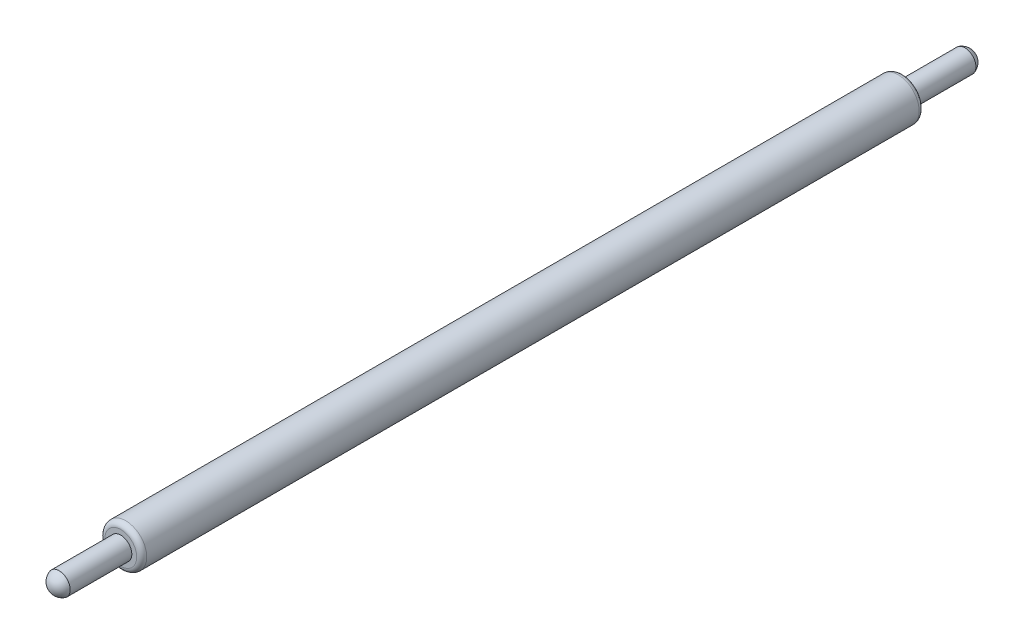
from build123d import *

# Parameters (mm, degrees)
ESQUISSE1_R             = 0.625
BOSS_EXTRU_1_DEPTH      = 11.662554
BOSS_EXTRU_1_DEPTH_BACK = 11.662554
ESQUISSE2_R             = 0.33
BOSS_EXTRU_2_DEPTH      = 1.837446
ESQUISSE3_R             = 0.33
BOSS_EXTRU_3_DEPTH      = 1.837446
D_ME1_FACE_RADIUS       = 0.33
D_ME1_HEIGHT            = 0.25
D_ME2_FACE_RADIUS       = 0.33
D_ME2_HEIGHT            = 0.25
CONG_1_R                = 0.15


with BuildPart() as part:
    # Esquisse1 → Boss.-Extru.1 (new body, two sides)
    with BuildSketch(Plane.XY) as boss_extru_1_sk:
        Circle(ESQUISSE1_R)
    extrude(amount=BOSS_EXTRU_1_DEPTH)
    extrude(boss_extru_1_sk.sketch, amount=-BOSS_EXTRU_1_DEPTH_BACK)

    # Esquisse2 → Boss.-Extru.2 (add)
    with BuildSketch(Plane.XY.offset(11.662554)):
        Circle(ESQUISSE2_R)
    extrude(amount=BOSS_EXTRU_2_DEPTH)

    # Esquisse3 → Boss.-Extru.3 (add)
    with BuildSketch(Plane(origin=(0, 0, -11.662554), x_dir=(-1, 0, 0), z_dir=(0, 0, -1))):
        Circle(ESQUISSE3_R)
    extrude(amount=BOSS_EXTRU_3_DEPTH)

    # D_me1: a dome of height H over a round flat face of radius A is a cap of a sphere of radius (A * A + H * H) / (2 * H)
    d_me1_r = (D_ME1_FACE_RADIUS * D_ME1_FACE_RADIUS + D_ME1_HEIGHT * D_ME1_HEIGHT) / (2 * D_ME1_HEIGHT)
    d_me1_base = Plane((0, 0, 13.5), z_dir=(0, 0, 1))
    with Locations(d_me1_base.offset(D_ME1_HEIGHT - d_me1_r)):
        d_me1_ball = Sphere(d_me1_r, mode=Mode.PRIVATE)
    add(split(d_me1_ball, bisect_by=d_me1_base, keep=Keep.TOP, mode=Mode.PRIVATE))

    # D_me2: a dome of height H over a round flat face of radius A is a cap of a sphere of radius (A * A + H * H) / (2 * H)
    d_me2_r = (D_ME2_FACE_RADIUS * D_ME2_FACE_RADIUS + D_ME2_HEIGHT * D_ME2_HEIGHT) / (2 * D_ME2_HEIGHT)
    d_me2_base = Plane((0, 0, -13.5), z_dir=(0, 0, -1))
    with Locations(d_me2_base.offset(D_ME2_HEIGHT - d_me2_r)):
        d_me2_ball = Sphere(d_me2_r, mode=Mode.PRIVATE)
    add(split(d_me2_ball, bisect_by=d_me2_base, keep=Keep.TOP, mode=Mode.PRIVATE))

    # Cong_1
    cong_1_edges = [part.edges().sort_by_distance(p)[0] for p in [
        (-0.625, 0, -11.662554),
        (-0.625, 0, 11.662554),
    ]]
    fillet(cong_1_edges, radius=CONG_1_R)


solid = part.part
